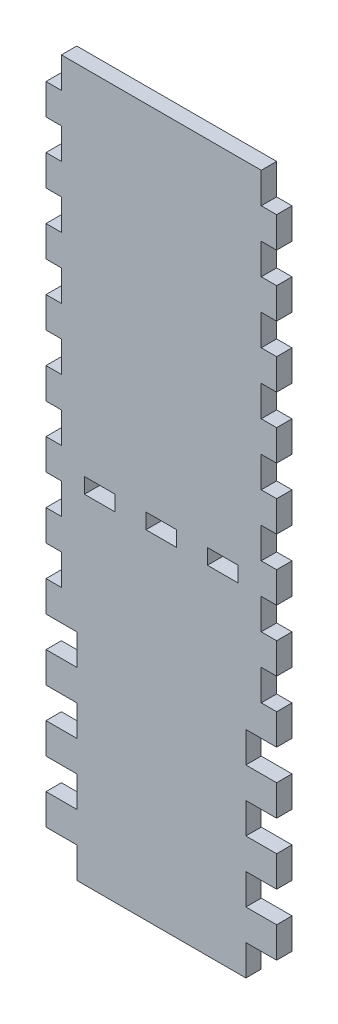
from build123d import *

# Parameters (mm, degrees)
SKETCH1_W           = 95.25
SKETCH1_H           = 292.1
BOSS_EXTRUDE1_DEPTH = 6.35
SKETCH2_W           = 6.35
SKETCH2_H           = 12.7
CUT_EXTRUDE1_DEPTH  = 7.35
LPATTERN1_COUNT     = 12
LPATTERN1_PITCH     = 25.4
SKETCH3_W           = 6.35
SKETCH3_H           = 12.7
CUT_EXTRUDE2_DEPTH  = 7.35
LPATTERN2_COUNT     = 4
LPATTERN2_PITCH     = 25.4
SKETCH4_W           = 12.7
SKETCH4_H           = 6.35
CUT_EXTRUDE3_DEPTH  = 7.35
LPATTERN3_COUNT     = 2
LPATTERN3_PITCH     = 25.4
LPATTERN3_COL_COUNT = 2
LPATTERN3_COL_PITCH = 25.4


with BuildPart() as part:
    # Sketch1 → Boss-Extrude1 (new body)
    with BuildSketch(Plane.XY):
        with Locations((47.625, 146.05)):
            Rectangle(SKETCH1_W, SKETCH1_H)
    extrude(amount=BOSS_EXTRUDE1_DEPTH)

    # Sketch2 → Cut-Extrude1 (cut, through all)
    with BuildSketch(Plane.XY.offset(6.35)):
        with Locations((3.175, 6.35)):
            Rectangle(SKETCH2_W, SKETCH2_H)
        with Locations((92.075, 6.35)):
            Rectangle(SKETCH2_W, SKETCH2_H)
    cut_extrude1 = extrude(amount=-CUT_EXTRUDE1_DEPTH, mode=Mode.SUBTRACT)

    # LPattern1: Cut-Extrude1 ×12
    with Locations(*[(0, i * LPATTERN1_PITCH, 0) for i in range(1, LPATTERN1_COUNT)]):
        add(cut_extrude1, mode=Mode.SUBTRACT)

    # Sketch3 → Cut-Extrude2 (cut, through all)
    with BuildSketch(Plane.XY.offset(6.35)):
        with Locations((85.725, 6.35)):
            Rectangle(SKETCH3_W, SKETCH3_H)
        with Locations((9.525, 6.35)):
            Rectangle(SKETCH3_W, SKETCH3_H)
    cut_extrude2 = extrude(amount=-CUT_EXTRUDE2_DEPTH, mode=Mode.SUBTRACT)

    # LPattern2: Cut-Extrude2 ×4
    with Locations(*[(0, i * LPATTERN2_PITCH, 0) for i in range(1, LPATTERN2_COUNT)]):
        add(cut_extrude2, mode=Mode.SUBTRACT)

    # Sketch4 → Cut-Extrude3 (cut, through all)
    with BuildSketch(Plane.XY.offset(6.35)):
        with Locations((47.625, 142.875)):
            Rectangle(SKETCH4_W, SKETCH4_H)
    cut_extrude3 = extrude(amount=-CUT_EXTRUDE3_DEPTH, mode=Mode.SUBTRACT)

    # LPattern3: Cut-Extrude3 ×2
    with Locations(*[(-i * LPATTERN3_PITCH, 0, 0) for i in range(1, LPATTERN3_COUNT)]):
        add(cut_extrude3, mode=Mode.SUBTRACT)

    # LPattern3 col: Cut-Extrude3 ×2
    with Locations(*[(i * LPATTERN3_COL_PITCH, 0, 0) for i in range(1, LPATTERN3_COL_COUNT)]):
        add(cut_extrude3, mode=Mode.SUBTRACT)


solid = part.part
